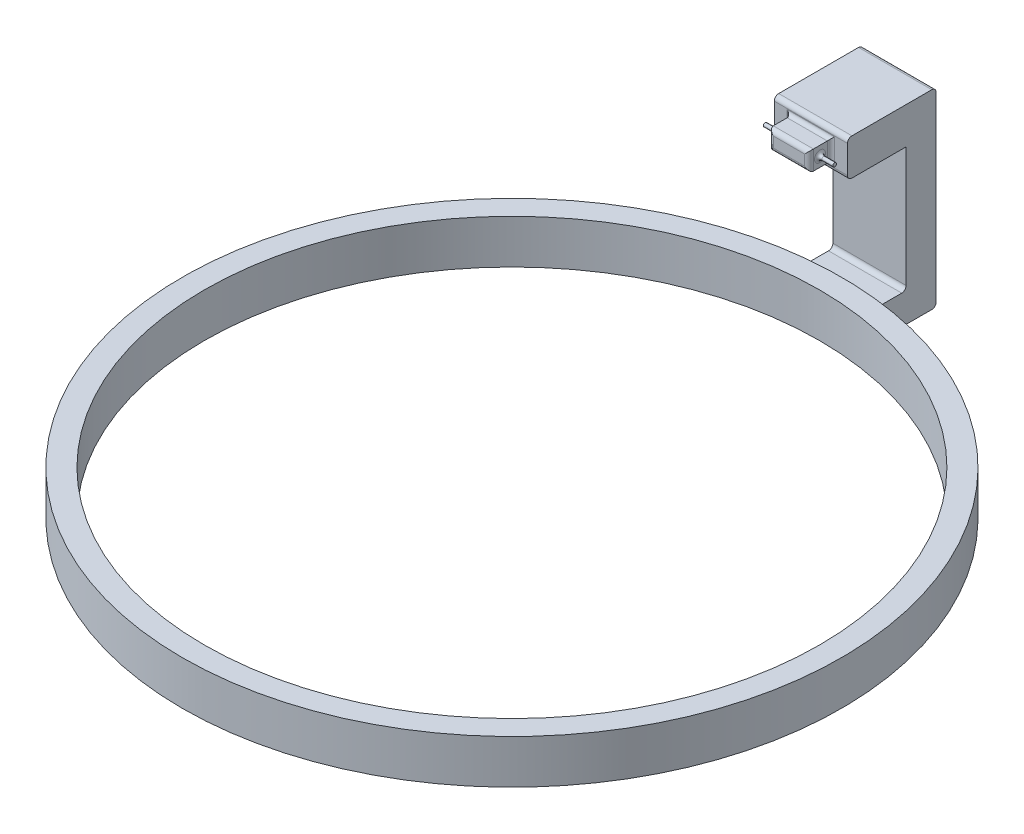
from build123d import *

# Parameters (mm, degrees)
SKETCH1_R               = 225
BOSS_EXTRUDE1_DEPTH     = 30
SKETCH2_R               = 210
CUT_EXTRUDE1_DEPTH      = 1
CUT_EXTRUDE1_DEPTH_BACK = 31
SKETCH3_W               = 50
SKETCH3_H               = 20
BOSS_EXTRUDE2_DEPTH     = 50
SKETCH4_W               = 50
SKETCH4_H               = 20.506281323
BOSS_EXTRUDE3_DEPTH     = 110
SKETCH5_W               = 50
SKETCH5_H               = 25
BOSS_EXTRUDE7_DEPTH     = 40
SKETCH6_W               = 27.39243627
SKETCH6_H               = 13.13
BOSS_EXTRUDE8_DEPTH     = 15
SKETCH7_R               = 1.25
BOSS_EXTRUDE9_DEPTH     = 10
SKETCH8_R               = 1.25
BOSS_EXTRUDE10_DEPTH    = 10
FILLET14_R              = 3
FILLET15_R              = 2.5
FILLET17_R              = 3


with BuildPart() as part:
    # Sketch1 → Boss-Extrude1 (new body)
    with BuildSketch(Plane(origin=(0, 0, 0), x_dir=(1, 0, 0), z_dir=(0, 1, 0))):
        Circle(SKETCH1_R)
    extrude(amount=BOSS_EXTRUDE1_DEPTH)

    # Sketch2 → Cut-Extrude1 (cut, two sides)
    with BuildSketch(Plane(origin=(0, 30, 0), x_dir=(1, 0, 0), z_dir=(0, 1, 0))) as cut_extrude1_sk:
        Circle(SKETCH2_R)
    extrude(amount=CUT_EXTRUDE1_DEPTH, mode=Mode.SUBTRACT)
    extrude(cut_extrude1_sk.sketch, amount=-CUT_EXTRUDE1_DEPTH_BACK, mode=Mode.SUBTRACT)

    # Sketch3 → Boss-Extrude2 (add)
    with BuildSketch(Plane.XY.offset(-214.619360396)):
        with Locations((0, 15)):
            Rectangle(SKETCH3_W, SKETCH3_H)
    extrude(amount=-BOSS_EXTRUDE2_DEPTH)

    # Sketch4 → Boss-Extrude3 (add)
    with BuildSketch(Plane(origin=(0, 25, 0), x_dir=(1, 0, 0), z_dir=(0, 1, 0))):
        with Locations((0, 254.366219735)):
            Rectangle(SKETCH4_W, SKETCH4_H)
    extrude(amount=BOSS_EXTRUDE3_DEPTH)

    # Sketch5 → Boss-Extrude7 (add)
    with BuildSketch(Plane.XY.offset(-244.113079073)):
        with Locations((0, 122.5)):
            Rectangle(SKETCH5_W, SKETCH5_H)
    extrude(amount=BOSS_EXTRUDE7_DEPTH)

    # Sketch6 → Boss-Extrude8 (add)
    with BuildSketch(Plane.XY.offset(-204.113079073)):
        with Locations((0, 122.5)):
            Rectangle(SKETCH6_W, SKETCH6_H)
    extrude(amount=BOSS_EXTRUDE8_DEPTH)

    # Sketch7 → Boss-Extrude9 (add)
    with BuildSketch(Plane.ZY.offset(13.696218135)):
        with Locations((-196.613079073, 122.5)):
            Circle(SKETCH7_R)
    extrude(amount=BOSS_EXTRUDE9_DEPTH)

    # Sketch8 → Boss-Extrude10 (add)
    with BuildSketch(Plane(origin=(13.696218135, 0, 0), x_dir=(0, 0, -1), z_dir=(1, 0, 0))):
        with Locations((196.613079073, 122.5)):
            Circle(SKETCH8_R)
    extrude(amount=BOSS_EXTRUDE10_DEPTH)

    # Fillet14
    fillet14_edges = [part.edges().sort_by_distance(p)[0] for p in [
        (-13.696218135, 122.5, -189.113079073),
        (0, 115.935, -189.113079073),
        (13.696218135, 122.5, -189.113079073),
        (0, 129.065, -189.113079073),
    ]]
    fillet(fillet14_edges, radius=FILLET14_R)

    # Fillet15
    fillet15_edges = [part.edges().sort_by_distance(p)[0] for p in [
        (-13.696218135, 122.5, -204.113079073),
        (0, 115.935, -204.113079073),
        (13.696218135, 122.5, -204.113079073),
        (0, 129.065, -204.113079073),
        (-13.696218135, 122.5, -197.863079073),
        (13.696218135, 122.5, -195.363079073),
    ]]
    fillet(fillet15_edges, radius=FILLET15_R)

    # Fillet17
    fillet17_edges = [part.edges().sort_by_distance(p)[0] for p in [
        (0, 25, -225),
        (-25, 15, -223.60679775),
        (0, 5, -225),
        (25, 15, -223.60679775),
        (0, 5, -264.619360396),
        (0, 25, -244.113079073),
        (0, 135, -264.619360396),
        (0, 110, -204.113079073),
        (0, 135, -204.113079073),
    ]]
    fillet(fillet17_edges, radius=FILLET17_R)


solid = part.part
